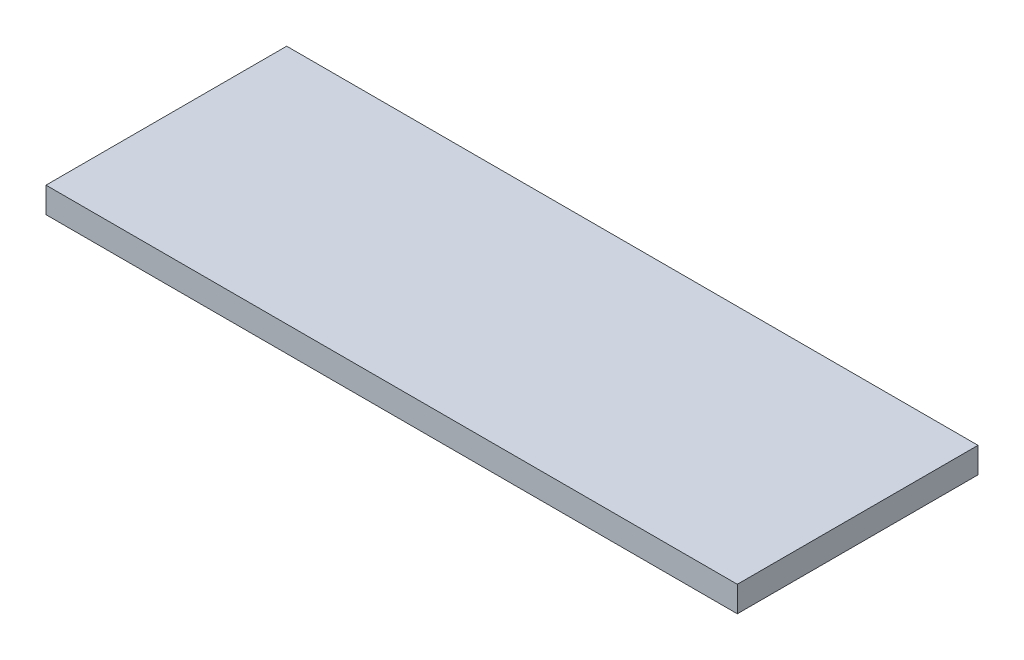
from build123d import *

# Parameters (mm, degrees)
SKETCH1_W           = 162
SKETCH1_H           = 56.4
BOSS_EXTRUDE1_DEPTH = 6


with BuildPart() as part:
    # Sketch1 → Boss-Extrude1 (new body)
    with BuildSketch(Plane(origin=(0, 0, 0), x_dir=(1, 0, 0), z_dir=(0, 1, 0))):
        Rectangle(SKETCH1_W, SKETCH1_H)
    extrude(amount=BOSS_EXTRUDE1_DEPTH)


solid = part.part
